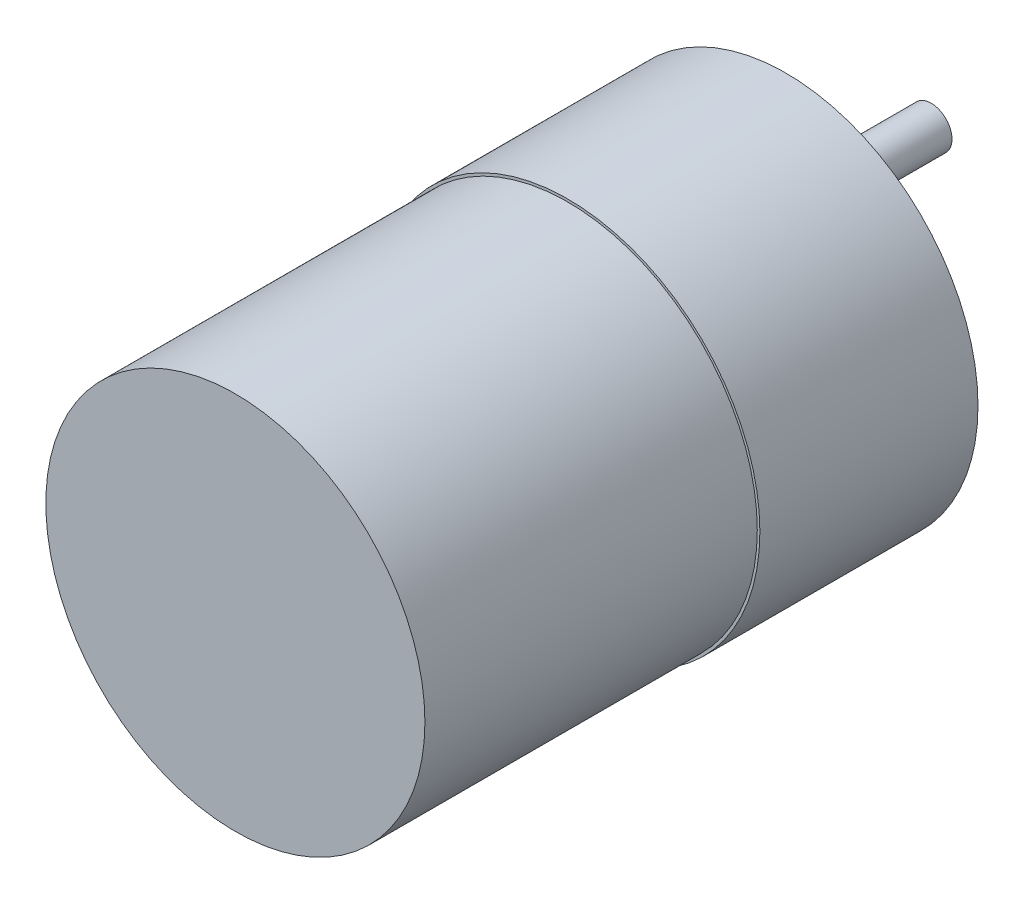
from build123d import *

# Parameters (mm, degrees)
MODEL_R                  = 18.5
MODEL_R_2                = 1.25
MODEL_R_3                = 6
RESSALTO_EXTRUS_O1_DEPTH = 21
ESBO_O2_R                = 18.25
RESSALTO_EXTRUS_O5_DEPTH = 32
ESBO_O3_R                = 6
RESSALTO_EXTRUS_O6_DEPTH = 27
ESBO_O4_R                = 2
RESSALTO_EXTRUS_O7_DEPTH = 15


with BuildPart() as part:
    # Model → Ressalto-extrusão1 (new body)
    with BuildSketch(Plane.XY):
        with Locations((7.003, 0.02)):
            Circle(MODEL_R)
        with Locations((20.777, -9.842)):
            Circle(MODEL_R_2, mode=Mode.SUBTRACT)
        with Locations((23.953, 0)):
            Circle(MODEL_R_2, mode=Mode.SUBTRACT)
        with Locations((20.777, 9.842)):
            Circle(MODEL_R_2, mode=Mode.SUBTRACT)
        with Locations((7.003, 16.95)):
            Circle(MODEL_R_2, mode=Mode.SUBTRACT)
        with Locations((-6.771, 9.842)):
            Circle(MODEL_R_2, mode=Mode.SUBTRACT)
        with Locations((-6.771, -9.842)):
            Circle(MODEL_R_2, mode=Mode.SUBTRACT)
        with Locations((7.003, -16.95)):
            Circle(MODEL_R_2, mode=Mode.SUBTRACT)
        Circle(MODEL_R_3, mode=Mode.SUBTRACT)
    extrude(amount=RESSALTO_EXTRUS_O1_DEPTH)

    # Esboço2 → Ressalto-extrusão5 (add)
    with BuildSketch(Plane.XY.offset(21)):
        with Locations((7.003, 0.02)):
            Circle(ESBO_O2_R)
    extrude(amount=RESSALTO_EXTRUS_O5_DEPTH)

    # Esboço3 → Ressalto-extrusão6 (add)
    with BuildSketch(Plane(origin=(0, 0, 21), x_dir=(-1, 0, 0), z_dir=(0, 0, -1))):
        Circle(ESBO_O3_R)
    extrude(amount=RESSALTO_EXTRUS_O6_DEPTH)

    # Esboço4 → Ressalto-extrusão7 (add)
    with BuildSketch(Plane(origin=(0, 0, -6), x_dir=(-1, 0, 0), z_dir=(0, 0, -1))):
        Circle(ESBO_O4_R)
    extrude(amount=RESSALTO_EXTRUS_O7_DEPTH)


solid = part.part
